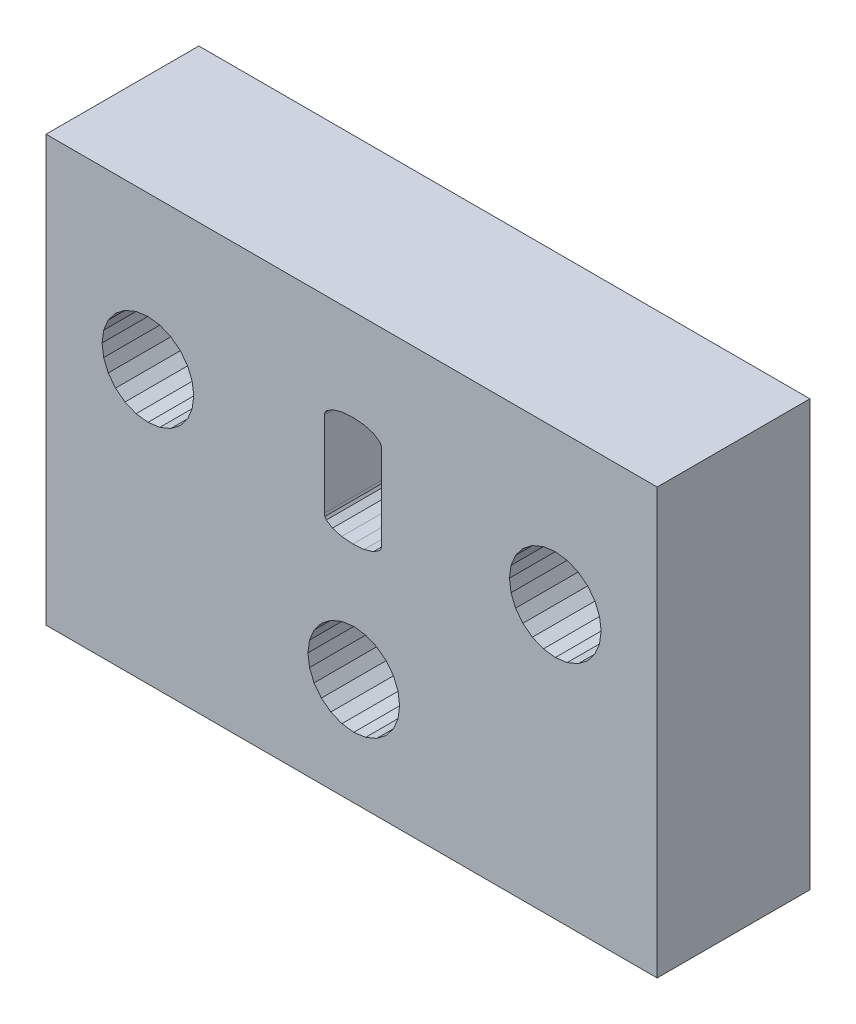
from build123d import *

# Parameters (mm, degrees)
SKETCH1_W           = 23.99999232
SKETCH1_H           = 16.699994656
BOSS_EXTRUDE1_DEPTH = 6


with BuildPart() as part:
    # Sketch1 → Boss-Extrude1 (new body)
    with BuildSketch(Plane.XY):
        with Locations((252.698883135, 107.632020418)):
            Rectangle(SKETCH1_W, SKETCH1_H)
        Polygon((246.437551626, 109.516145534), (246.498885119, 109.982019666), (246.437551626, 110.447893798), (246.257730923, 110.882019378), (245.971677493, 111.254811465), (245.598885407, 111.540864894), (245.164759827, 111.720685597), (244.698885695, 111.78201909), (244.233011562, 111.720685597), (243.798885983, 111.540864894), (243.426093896, 111.254811465), (243.140040467, 110.882019378), (242.960219764, 110.447893798), (242.898886271, 109.982019666), (242.960219764, 109.516145534), (243.140040467, 109.082019954), (243.426093896, 108.709227867), (243.798885983, 108.423174438), (244.233011562, 108.243353735), (244.698885695, 108.182020242), (245.164759827, 108.243353735), (245.598885407, 108.423174438), (245.971677493, 108.709227867), (246.257730923, 109.082019954), align=None, mode=Mode.SUBTRACT)
        Polygon((258.959098233, 109.516145534), (259.138918936, 109.082019954), (259.424972365, 108.709227867), (259.797764452, 108.423174438), (260.231890032, 108.243353735), (260.697764164, 108.182020242), (261.163638296, 108.243353735), (261.597763876, 108.423174438), (261.970555963, 108.709227867), (262.256609392, 109.082019954), (262.436430095, 109.516145534), (262.497763588, 109.982019666), (262.436430095, 110.447893798), (262.256609392, 110.882019378), (261.970555963, 111.254811465), (261.597763876, 111.540864894), (261.163638296, 111.720685597), (260.697764164, 111.78201909), (260.231890032, 111.720685597), (259.797764452, 111.540864894), (259.424972365, 111.254811465), (259.138918936, 110.882019378), (258.959098233, 110.447893798), (258.89776474, 109.982019666), align=None, mode=Mode.SUBTRACT)
        Polygon((251.044981368, 103.947895878), (250.983647875, 103.482021746), (251.044981368, 103.016147614), (251.224802071, 102.582022034), (251.5108555, 102.209229947), (251.883647587, 101.923176518), (252.317773167, 101.743355815), (252.783647299, 101.682022322), (253.249521431, 101.743355815), (253.683647011, 101.923176518), (254.056439098, 102.209229947), (254.342492527, 102.582022034), (254.52231323, 103.016147614), (254.583646723, 103.482021746), (254.52231323, 103.947895878), (254.342492527, 104.382021458), (254.056439098, 104.754813545), (253.683647011, 105.040866974), (253.249521431, 105.220687677), (252.783647299, 105.28202117), (252.317773167, 105.220687677), (251.883647587, 105.040866974), (251.5108555, 104.754813545), (251.224802071, 104.382021458), align=None, mode=Mode.SUBTRACT)
        Polygon((251.626522607, 108.549297627), (251.646619549, 108.453109198), (251.706910374, 108.364334307), (251.948073674, 108.209025142), (252.309437527, 108.103663575), (252.750426951, 108.068543053), (253.191416376, 108.103663575), (253.552780229, 108.209025142), (253.793943529, 108.364334307), (253.854234354, 108.453109198), (253.874331296, 108.549297627), (253.874331296, 111.895715309), (253.854234354, 111.991903738), (253.793943529, 112.080678629), (253.552780229, 112.235987794), (253.191416376, 112.341349361), (252.750426951, 112.376469883), (252.309437527, 112.341349361), (251.948073674, 112.235987794), (251.706910374, 112.080678629), (251.646619549, 111.991903738), (251.626522607, 111.895715309), align=None, mode=Mode.SUBTRACT)
    extrude(amount=BOSS_EXTRUDE1_DEPTH)


solid = part.part
